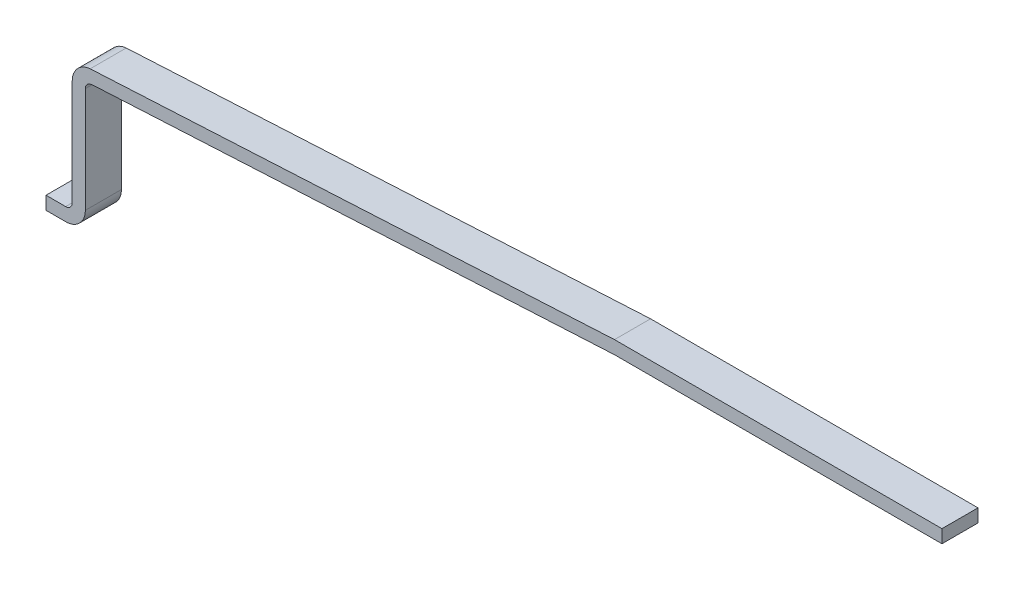
from build123d import *

# Parameters (mm, degrees)
RESSALTO_EXTRUS_O1_DEPTH = 0.55


with BuildPart() as part:
    # Esboço1 → Ressalto-extrusão1 (new body)
    with BuildSketch(Plane.XY):
        with BuildLine():
            Line((-0.319177055, 12.471030264), (-0.019177055, 12.471030264))
            ThreePointArc((-0.019177055, 12.471030264), (0.051533624, 12.500319586), (0.080822945, 12.571030264))
            Line((0.080822945, 12.571030264), (0.080822945, 14.179397147))
            ThreePointArc((0.080822945, 14.179397147), (0.159639744, 14.382074209), (0.354676223, 14.478255556))
            Line((0.354676223, 14.478255556), (8.354366094, 14.9))
            Line((8.354366094, 14.9), (13.35, 14.9))
            Line((13.35, 14.9), (13.35, 14.7))
            Line((13.35, 14.7), (8.354366094, 14.7))
            Line((8.354366094, 14.7), (0.432418849, 14.285057155))
            Line((0.432418849, 14.285057155), (0.372107371, 14.279016616))
            ThreePointArc((0.372107371, 14.279016616), (0.307095212, 14.246956167), (0.280822945, 14.179397147))
            Line((0.280822945, 14.179397147), (0.280822945, 12.571030264))
            ThreePointArc((0.280822945, 12.571030264), (0.19295498, 12.35889823), (-0.019177055, 12.271030264))
            Line((-0.019177055, 12.271030264), (-0.319177055, 12.271030264))
            Line((-0.319177055, 12.271030264), (-0.319177055, 12.471030264))
        make_face()
    extrude(amount=RESSALTO_EXTRUS_O1_DEPTH)


solid = part.part
